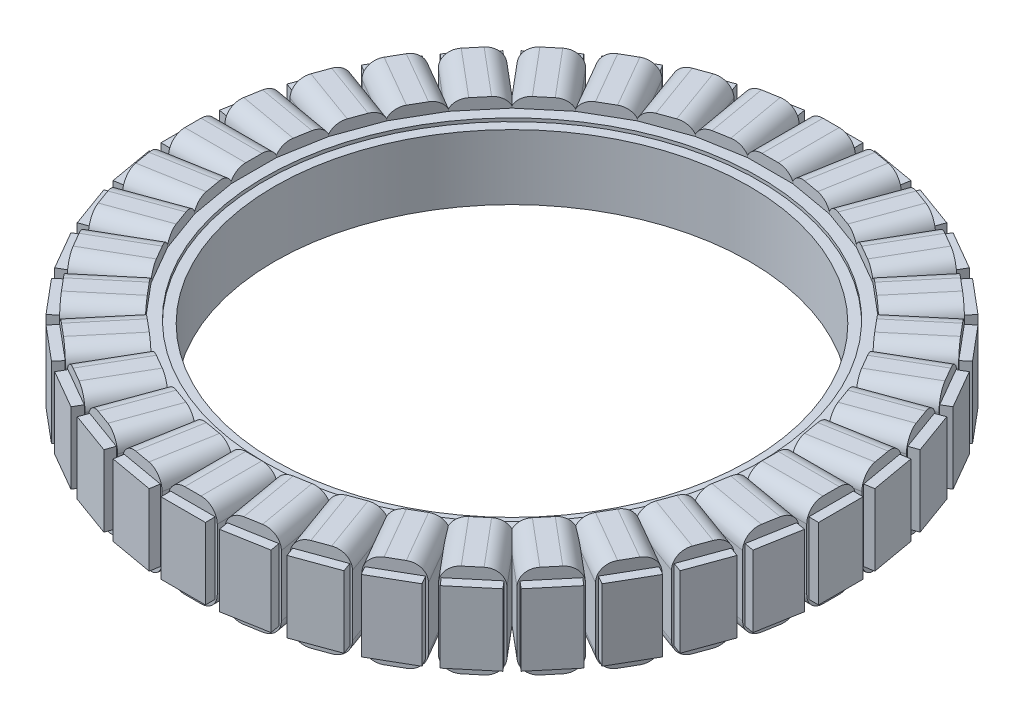
from build123d import *

# Parameters (mm, degrees)
SKETCH1_R           = 30.45
SKETCH1_R_2         = 29.25
BOSS_EXTRUDE1_DEPTH = 4
SKETCH2_R           = 30.45
BOSS_EXTRUDE2_DEPTH = 4.4
CUT_EXTRUDE1_DEPTH  = 8.8
BOSS_EXTRUDE3_DEPTH = 7.5
CIRPATTERN1_COUNT   = 36


with BuildPart() as part:
    # Sketch1 → Boss-Extrude1 (new body, symmetric)
    with BuildSketch(Plane(origin=(0, 0, 0), x_dir=(1, 0, 0), z_dir=(0, 1, 0))):
        Circle(SKETCH1_R)
        Circle(SKETCH1_R_2, mode=Mode.SUBTRACT)
    extrude(amount=BOSS_EXTRUDE1_DEPTH, both=True)

    # Sketch2 → Boss-Extrude2 (add, symmetric)
    with BuildSketch(Plane(origin=(0, 0, 0), x_dir=(1, 0, 0), z_dir=(0, 1, 0))):
        Polygon((-3.543290873, 40.5), (-10.522211518, 39.269427994), (-17.181420091, 36.84567429), (-23.318579909, 33.302383417), (-28.747216476, 28.747216476), (-33.302383417, 23.318579909), (-36.84567429, 17.181420091), (-39.269427994, 10.522211518), (-40.5, 3.543290873), (-40.5, -3.543290873), (-39.269427994, -10.522211518), (-36.84567429, -17.181420091), (-33.302383417, -23.318579909), (-28.747216476, -28.747216476), (-23.318579909, -33.302383417), (-17.181420091, -36.84567429), (-10.522211518, -39.269427994), (-3.543290873, -40.5), (3.543290873, -40.5), (10.522211518, -39.269427994), (17.181420091, -36.84567429), (23.318579909, -33.302383417), (28.747216476, -28.747216476), (33.302383417, -23.318579909), (36.84567429, -17.181420091), (39.269427994, -10.522211518), (40.5, -3.543290873), (40.5, 3.543290873), (39.269427994, 10.522211518), (36.84567429, 17.181420091), (33.302383417, 23.318579909), (28.747216476, 28.747216476), (23.318579909, 33.302383417), (17.181420091, 36.84567429), (10.522211518, 39.269427994), (3.543290873, 40.5), align=None)
        Circle(SKETCH2_R, mode=Mode.SUBTRACT)
    extrude(amount=BOSS_EXTRUDE2_DEPTH, both=True)

    # Sketch4 → Cut-Extrude1 (cut)
    with BuildSketch(Plane(origin=(0, 4.4, 0), x_dir=(1, 0, 0), z_dir=(0, 1, 0))):
        Polygon((1, 39.3), (2.740235003, 39.3), (2.740235003, 40.5), (3.543290873, 40.5), (4.33414652, 40.360550812), (4.125768707, 39.178781508), (5.839565629, 38.876592871), (4.569251962, 31.672286062), (1, 31.984555146), align=None)
        Polygon((7.809181135, 38.529296516), (9.522978058, 38.227107879), (9.731355871, 39.408877182), (10.522211518, 39.269427994), (11.276837193, 38.99476671), (10.866413021, 37.867135565), (12.501699012, 37.27194014), (9.999669514, 30.397670593), (6.538867468, 31.324989707), align=None)
        Polygon((14.381084253, 36.587899854), (16.016370244, 35.992704428), (16.426794416, 37.120335573), (17.181420091, 36.84567429), (17.876886875, 36.444146355), (17.276886875, 35.40491587), (18.783974596, 34.534798369), (15.126252169, 28.199437285), (11.879054756, 29.713630306), align=None)
        Polygon((20.516025404, 33.534798369), (22.023113125, 32.664680867), (22.623113125, 33.703911352), (23.318579909, 33.302383417), (23.933756396, 32.786189054), (23.162411264, 31.866935722), (24.495508618, 30.748334224), (19.793231306, 25.144378345), (16.858302977, 27.199437285), align=None)
        Polygon((26.027597504, 29.462759005), (27.360694857, 28.344157507), (28.132039989, 29.263410839), (28.747216476, 28.747216476), (29.263410839, 28.132039989), (28.344157507, 27.360694857), (29.462759005, 26.027597504), (23.858803126, 21.325320192), (21.325320192, 23.858803126), align=None)
        Polygon((30.748334224, 24.495508618), (31.866935722, 23.162411264), (32.786189054, 23.933756396), (33.302383417, 23.318579909), (33.703911352, 22.623113125), (32.664680867, 22.023113125), (33.534798369, 20.516025404), (27.199437285, 16.858302977), (25.144378345, 19.793231306), align=None)
        Polygon((34.534798369, 18.783974596), (35.40491587, 17.276886875), (36.444146355, 17.876886875), (36.84567429, 17.181420091), (37.120335573, 16.426794416), (35.992704428, 16.016370244), (36.587899854, 14.381084253), (29.713630306, 11.879054756), (28.199437285, 15.126252169), align=None)
        Polygon((37.27194014, 12.501699012), (37.867135565, 10.866413021), (38.99476671, 11.276837193), (39.269427994, 10.522211518), (39.408877182, 9.731355871), (38.227107879, 9.522978058), (38.529296516, 7.809181135), (31.324989707, 6.538867468), (30.397670593, 9.999669514), align=None)
        Polygon((38.876592871, 5.839565629), (39.178781508, 4.125768707), (40.360550812, 4.33414652), (40.5, 3.543290873), (40.5, 2.740235003), (39.3, 2.740235003), (39.3, 1), (31.984555146, 1), (31.672286062, 4.569251962), align=None)
        Polygon((39.3, -1), (39.3, -2.740235003), (40.5, -2.740235003), (40.5, -3.543290873), (40.360550812, -4.33414652), (39.178781508, -4.125768707), (38.876592871, -5.839565629), (31.672286062, -4.569251962), (31.984555146, -1), align=None)
        Polygon((38.529296516, -7.809181135), (38.227107879, -9.522978058), (39.408877182, -9.731355871), (39.269427994, -10.522211518), (38.99476671, -11.276837193), (37.867135565, -10.866413021), (37.27194014, -12.501699012), (30.397670593, -9.999669514), (31.324989707, -6.538867468), align=None)
        Polygon((36.587899854, -14.381084253), (35.992704428, -16.016370244), (37.120335573, -16.426794416), (36.84567429, -17.181420091), (36.444146355, -17.876886875), (35.40491587, -17.276886875), (34.534798369, -18.783974596), (28.199437285, -15.126252169), (29.713630306, -11.879054756), align=None)
        Polygon((33.534798369, -20.516025404), (32.664680867, -22.023113125), (33.703911352, -22.623113125), (33.302383417, -23.318579909), (32.786189054, -23.933756396), (31.866935722, -23.162411264), (30.748334224, -24.495508618), (25.144378345, -19.793231306), (27.199437285, -16.858302977), align=None)
        Polygon((29.462759005, -26.027597504), (28.344157507, -27.360694857), (29.263410839, -28.132039989), (28.747216476, -28.747216476), (28.132039989, -29.263410839), (27.360694857, -28.344157507), (26.027597504, -29.462759005), (21.325320192, -23.858803126), (23.858803126, -21.325320192), align=None)
        Polygon((24.495508618, -30.748334224), (23.162411264, -31.866935722), (23.933756396, -32.786189054), (23.318579909, -33.302383417), (22.623113125, -33.703911352), (22.023113125, -32.664680867), (20.516025404, -33.534798369), (16.858302977, -27.199437285), (19.793231306, -25.144378345), align=None)
        Polygon((18.783974596, -34.534798369), (17.276886875, -35.40491587), (17.876886875, -36.444146355), (17.181420091, -36.84567429), (16.426794416, -37.120335573), (16.016370244, -35.992704428), (14.381084253, -36.587899854), (11.879054756, -29.713630306), (15.126252169, -28.199437285), align=None)
        Polygon((12.501699012, -37.27194014), (10.866413021, -37.867135565), (11.276837193, -38.99476671), (10.522211518, -39.269427994), (9.731355871, -39.408877182), (9.522978058, -38.227107879), (7.809181135, -38.529296516), (6.538867468, -31.324989707), (9.999669514, -30.397670593), align=None)
        Polygon((5.839565629, -38.876592871), (4.125768707, -39.178781508), (4.33414652, -40.360550812), (3.543290873, -40.5), (2.740235003, -40.5), (2.740235003, -39.3), (1, -39.3), (1, -31.984555146), (4.569251962, -31.672286062), align=None)
        Polygon((-1, -39.3), (-2.740235003, -39.3), (-2.740235003, -40.5), (-3.543290873, -40.5), (-4.33414652, -40.360550812), (-4.125768707, -39.178781508), (-5.839565629, -38.876592871), (-4.569251962, -31.672286062), (-1, -31.984555146), align=None)
        Polygon((-7.809181135, -38.529296516), (-9.522978058, -38.227107879), (-9.731355871, -39.408877182), (-10.522211518, -39.269427994), (-11.276837193, -38.99476671), (-10.866413021, -37.867135565), (-12.501699012, -37.27194014), (-9.999669514, -30.397670593), (-6.538867468, -31.324989707), align=None)
        Polygon((-14.381084253, -36.587899854), (-16.016370244, -35.992704428), (-16.426794416, -37.120335573), (-17.181420091, -36.84567429), (-17.876886875, -36.444146355), (-17.276886875, -35.40491587), (-18.783974596, -34.534798369), (-15.126252169, -28.199437285), (-11.879054756, -29.713630306), align=None)
        Polygon((-20.516025404, -33.534798369), (-22.023113125, -32.664680867), (-22.623113125, -33.703911352), (-23.318579909, -33.302383417), (-23.933756396, -32.786189054), (-23.162411264, -31.866935722), (-24.495508618, -30.748334224), (-19.793231306, -25.144378345), (-16.858302977, -27.199437285), align=None)
        Polygon((-26.027597504, -29.462759005), (-27.360694857, -28.344157507), (-28.132039989, -29.263410839), (-28.747216476, -28.747216476), (-29.263410839, -28.132039989), (-28.344157507, -27.360694857), (-29.462759005, -26.027597504), (-23.858803126, -21.325320192), (-21.325320192, -23.858803126), align=None)
        Polygon((-30.748334224, -24.495508618), (-31.866935722, -23.162411264), (-32.786189054, -23.933756396), (-33.302383417, -23.318579909), (-33.703911352, -22.623113125), (-32.664680867, -22.023113125), (-33.534798369, -20.516025404), (-27.199437285, -16.858302977), (-25.144378345, -19.793231306), align=None)
        Polygon((-34.534798369, -18.783974596), (-35.40491587, -17.276886875), (-36.444146355, -17.876886875), (-36.84567429, -17.181420091), (-37.120335573, -16.426794416), (-35.992704428, -16.016370244), (-36.587899854, -14.381084253), (-29.713630306, -11.879054756), (-28.199437285, -15.126252169), align=None)
        Polygon((-37.27194014, -12.501699012), (-37.867135565, -10.866413021), (-38.99476671, -11.276837193), (-39.269427994, -10.522211518), (-39.408877182, -9.731355871), (-38.227107879, -9.522978058), (-38.529296516, -7.809181135), (-31.324989707, -6.538867468), (-30.397670593, -9.999669514), align=None)
        Polygon((-38.876592871, -5.839565629), (-39.178781508, -4.125768707), (-40.360550812, -4.33414652), (-40.5, -3.543290873), (-40.5, -2.740235003), (-39.3, -2.740235003), (-39.3, -1), (-31.984555146, -1), (-31.672286062, -4.569251962), align=None)
        Polygon((-39.3, 1), (-39.3, 2.740235003), (-40.5, 2.740235003), (-40.5, 3.543290873), (-40.360550812, 4.33414652), (-39.178781508, 4.125768707), (-38.876592871, 5.839565629), (-31.672286062, 4.569251962), (-31.984555146, 1), align=None)
        Polygon((-38.529296516, 7.809181135), (-38.227107879, 9.522978058), (-39.408877182, 9.731355871), (-39.269427994, 10.522211518), (-38.99476671, 11.276837193), (-37.867135565, 10.866413021), (-37.27194014, 12.501699012), (-30.397670593, 9.999669514), (-31.324989707, 6.538867468), align=None)
        Polygon((-36.587899854, 14.381084253), (-35.992704428, 16.016370244), (-37.120335573, 16.426794416), (-36.84567429, 17.181420091), (-36.444146355, 17.876886875), (-35.40491587, 17.276886875), (-34.534798369, 18.783974596), (-28.199437285, 15.126252169), (-29.713630306, 11.879054756), align=None)
        Polygon((-33.534798369, 20.516025404), (-32.664680867, 22.023113125), (-33.703911352, 22.623113125), (-33.302383417, 23.318579909), (-32.786189054, 23.933756396), (-31.866935722, 23.162411264), (-30.748334224, 24.495508618), (-25.144378345, 19.793231306), (-27.199437285, 16.858302977), align=None)
        Polygon((-29.462759005, 26.027597504), (-28.344157507, 27.360694857), (-29.263410839, 28.132039989), (-28.747216476, 28.747216476), (-28.132039989, 29.263410839), (-27.360694857, 28.344157507), (-26.027597504, 29.462759005), (-21.325320192, 23.858803126), (-23.858803126, 21.325320192), align=None)
        Polygon((-24.495508618, 30.748334224), (-23.162411264, 31.866935722), (-23.933756396, 32.786189054), (-23.318579909, 33.302383417), (-22.623113125, 33.703911352), (-22.023113125, 32.664680867), (-20.516025404, 33.534798369), (-16.858302977, 27.199437285), (-19.793231306, 25.144378345), align=None)
        Polygon((-18.783974596, 34.534798369), (-17.276886875, 35.40491587), (-17.876886875, 36.444146355), (-17.181420091, 36.84567429), (-16.426794416, 37.120335573), (-16.016370244, 35.992704428), (-14.381084253, 36.587899854), (-11.879054756, 29.713630306), (-15.126252169, 28.199437285), align=None)
        Polygon((-12.501699012, 37.27194014), (-10.866413021, 37.867135565), (-11.276837193, 38.99476671), (-10.522211518, 39.269427994), (-9.731355871, 39.408877182), (-9.522978058, 38.227107879), (-7.809181135, 38.529296516), (-6.538867468, 31.324989707), (-9.999669514, 30.397670593), align=None)
        Polygon((-5.839565629, 38.876592871), (-4.125768707, 39.178781508), (-4.33414652, 40.360550812), (-3.543290873, 40.5), (-2.740235003, 40.5), (-2.740235003, 39.3), (-1, 39.3), (-1, 31.984555146), (-4.569251962, 31.672286062), align=None)
    extrude(amount=-CUT_EXTRUDE1_DEPTH, mode=Mode.SUBTRACT)

    # Sketch5 → Boss-Extrude3 (add)
    with BuildSketch(Plane.XY.offset(-39.3)):
        with BuildLine():
            Line((1, 5.75), (-1, 5.75))
            ThreePointArc((-1, 5.75), (-2.414213562, 5.164213562), (-3, 3.75))
            Line((-3, 3.75), (-3, -3.75))
            ThreePointArc((-3, -3.75), (-2.414213562, -5.164213562), (-1, -5.75))
            Line((-1, -5.75), (1, -5.75))
            ThreePointArc((1, -5.75), (2.414213562, -5.164213562), (3, -3.75))
            Line((3, -3.75), (3, 3.75))
            ThreePointArc((3, 3.75), (2.414213562, 5.164213562), (1, 5.75))
        make_face()
    boss_extrude3 = extrude(amount=BOSS_EXTRUDE3_DEPTH)

    # CirPattern1: Boss-Extrude3 ×36 about axis
    cirpattern1_axis = Axis((0, 0, 0), (0, 1, 0))
    for i in range(1, CIRPATTERN1_COUNT):
        add(boss_extrude3.rotate(cirpattern1_axis, i * 360 / CIRPATTERN1_COUNT))


solid = part.part
